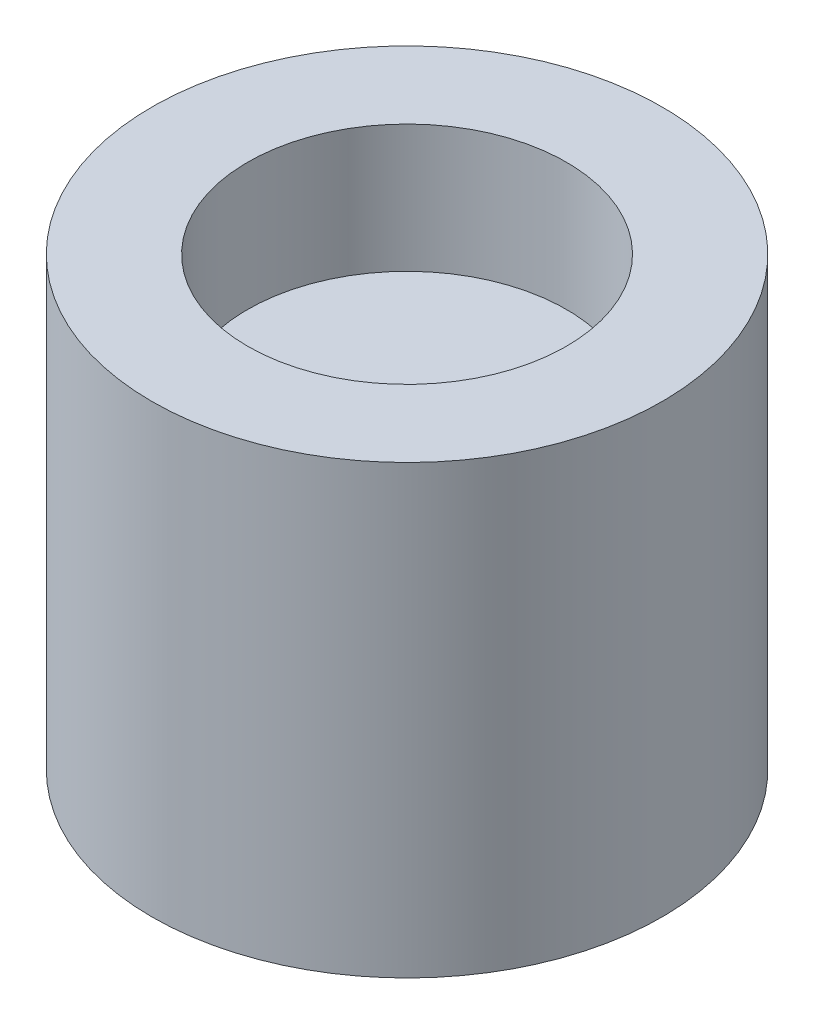
from build123d import *

# Parameters (mm, degrees)
SKETCH1_R           = 5.08
BOSS_EXTRUDE1_DEPTH = 8.89
CUT_EXTRUDE1_DEPTH  = 3.81
SKETCH3_R           = 3.175
CUT_EXTRUDE2_DEPTH  = 2.54


with BuildPart() as part:
    # Sketch1 → Boss-Extrude1 (new body)
    with BuildSketch(Plane(origin=(0, 0, 0), x_dir=(1, 0, 0), z_dir=(0, 1, 0))):
        Circle(SKETCH1_R)
    extrude(amount=BOSS_EXTRUDE1_DEPTH)

    # Sketch2 → Cut-Extrude1 (cut)
    with BuildSketch(Plane(origin=(0, 0, 0), x_dir=(1, 0, 0), z_dir=(0, 1, 0))):
        with BuildLine():
            Line((-2.794, 1.987864432), (-2.794, -1.987864432))
            ThreePointArc((-2.794, -1.987864432), (1.043411472, -3.266394572), (3.429, 0))
            ThreePointArc((3.429, 0), (1.043411472, 3.266394572), (-2.794, 1.987864432))
        make_face()
    extrude(amount=CUT_EXTRUDE1_DEPTH, mode=Mode.SUBTRACT)

    # Sketch3 → Cut-Extrude2 (cut)
    with BuildSketch(Plane(origin=(0, 8.89, 0), x_dir=(1, 0, 0), z_dir=(0, 1, 0))):
        Circle(SKETCH3_R)
    extrude(amount=-CUT_EXTRUDE2_DEPTH, mode=Mode.SUBTRACT)


solid = part.part
